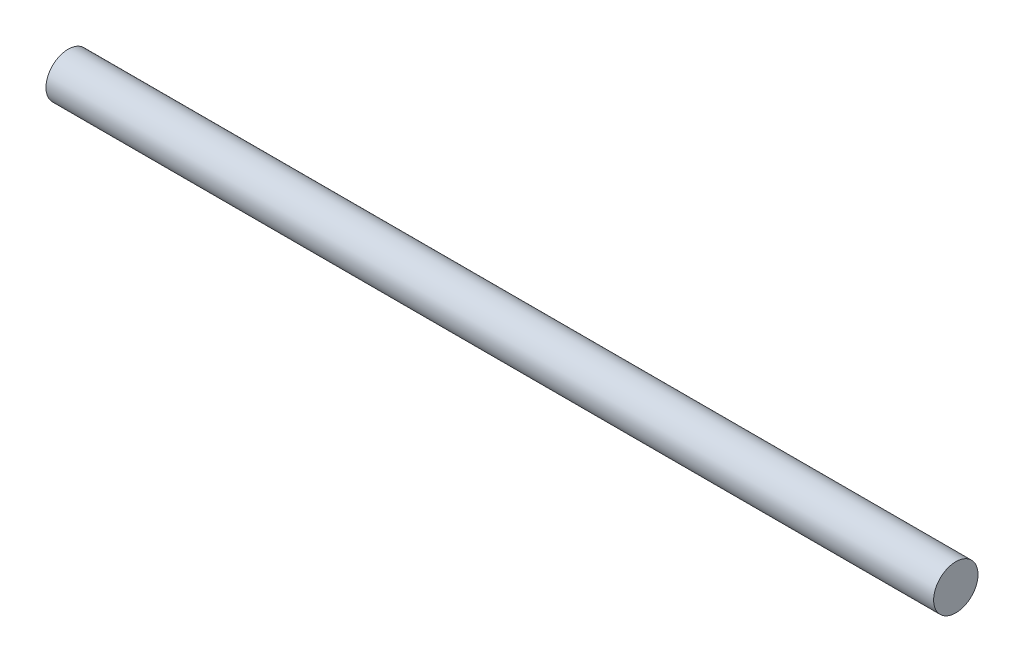
from build123d import *

# Parameters (mm, degrees)
SKETCH1_R            = 1
DC_MOTOR_SHAFT_DEPTH = 20


with BuildPart() as part:
    # Sketch1 → DC MOTOR SHAFT (new body, symmetric)
    with BuildSketch(Plane(origin=(0, 0, 0), x_dir=(0, 0, -1), z_dir=(1, 0, 0))):
        Circle(SKETCH1_R)
    extrude(amount=DC_MOTOR_SHAFT_DEPTH, both=True)


solid = part.part
